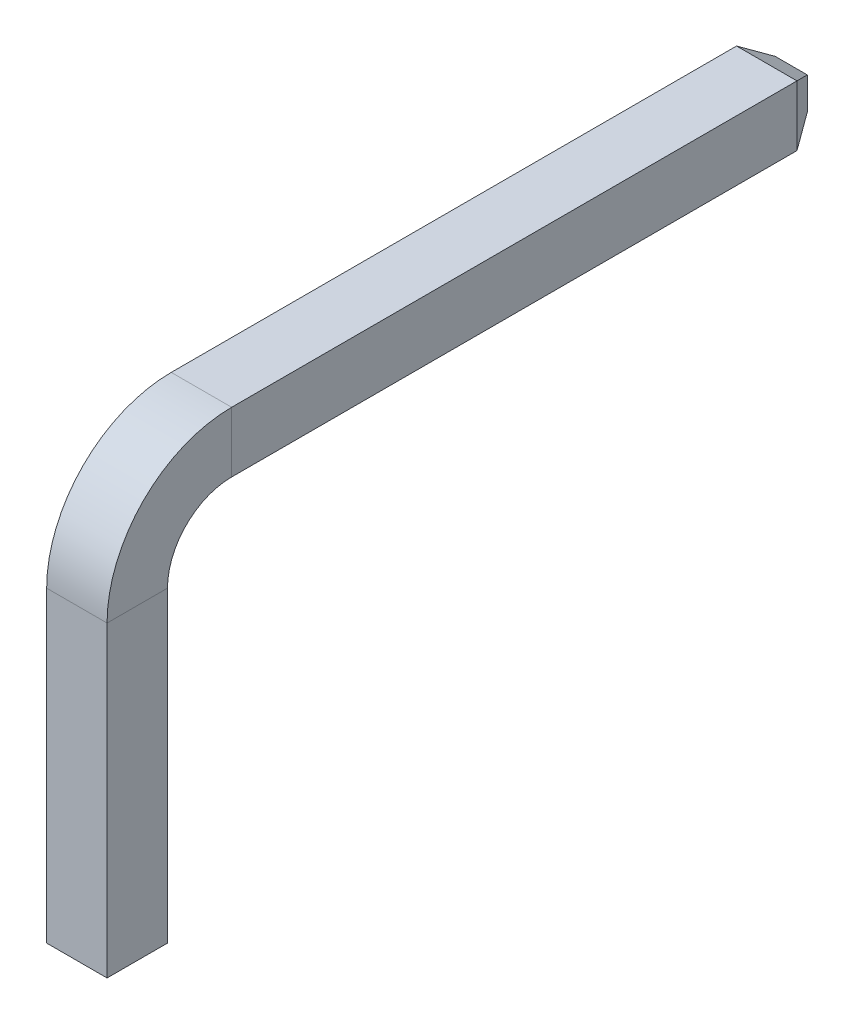
from build123d import *

# Parameters (mm, degrees)
SKETCH_3_W             = 0.64
SKETCH_3_H             = 0.64
CHAMFER_1_SIZE         = 0.15
CHAMFER_1_SIZE2        = 0.259807621
CHAMFER_1_PART_2_SIZE  = 0.15
CHAMFER_1_PART_2_SIZE2 = 0.259807621
SKETCH1_W              = 0.64
SKETCH1_H              = 4.734584987
CUT_EXTRUDE1_DEPTH     = 8.57


with BuildPart() as part:
    # Sweep 1: sweep along a path in Sketch 2
    with BuildLine(Plane(origin=(0, 0, 0), x_dir=(0, 0, -1), z_dir=(1, 0, 0))) as sweep_1_path:
        Line((0, -3), (0, 0))
        Line((0, 0), (0, 4.75))
        ThreePointArc((0, 4.75), (0.292893219, 5.457106781), (1, 5.75))
        Line((1, 5.75), (7.25, 5.75))
    # Sketch 3 → Sweep 1 (sweep)
    with BuildSketch(Plane(origin=(0, 0, 0), x_dir=(1, 0, 0), z_dir=(0, 1, 0))):
        Rectangle(SKETCH_3_W, SKETCH_3_H)
    sweep(path=sweep_1_path.line)

    # Chamfer 1
    chamfer_1_edges = [part.edges().sort_by_distance(p)[0] for p in [
        (0, 5.43, -7.25),
        (-0.32, 5.75, -7.25),
        (0, 6.07, -7.25),
        (0.32, 5.75, -7.25),
    ]]
    chamfer_1_side = [part.faces().sort_by_distance(p)[0] for p in [
        (0, 5.75, -7.25),
    ]]
    chamfer(chamfer_1_edges, length=CHAMFER_1_SIZE, length2=CHAMFER_1_SIZE2, reference=chamfer_1_side[0])

    # Chamfer 1 part 2
    chamfer_1_part_2_edges = [part.edges().sort_by_distance(p)[0] for p in [
        (0.32, -3, 0),
        (0, -3, -0.32),
        (-0.32, -3, 0),
        (0, -3, 0.32),
    ]]
    chamfer_1_part_2_side = [part.faces().sort_by_distance(p)[0] for p in [
        (0, -3, 0),
    ]]
    chamfer(chamfer_1_part_2_edges, length=CHAMFER_1_PART_2_SIZE, length2=CHAMFER_1_PART_2_SIZE2, reference=chamfer_1_part_2_side[0])

    # Sketch1 → Cut-Extrude1 (cut, through all)
    with BuildSketch(Plane.XY.offset(0.32)):
        with Locations((0, -0.874507109)):
            Rectangle(SKETCH1_W, SKETCH1_H)
    extrude(amount=-CUT_EXTRUDE1_DEPTH, mode=Mode.SUBTRACT)


solid = part.part
